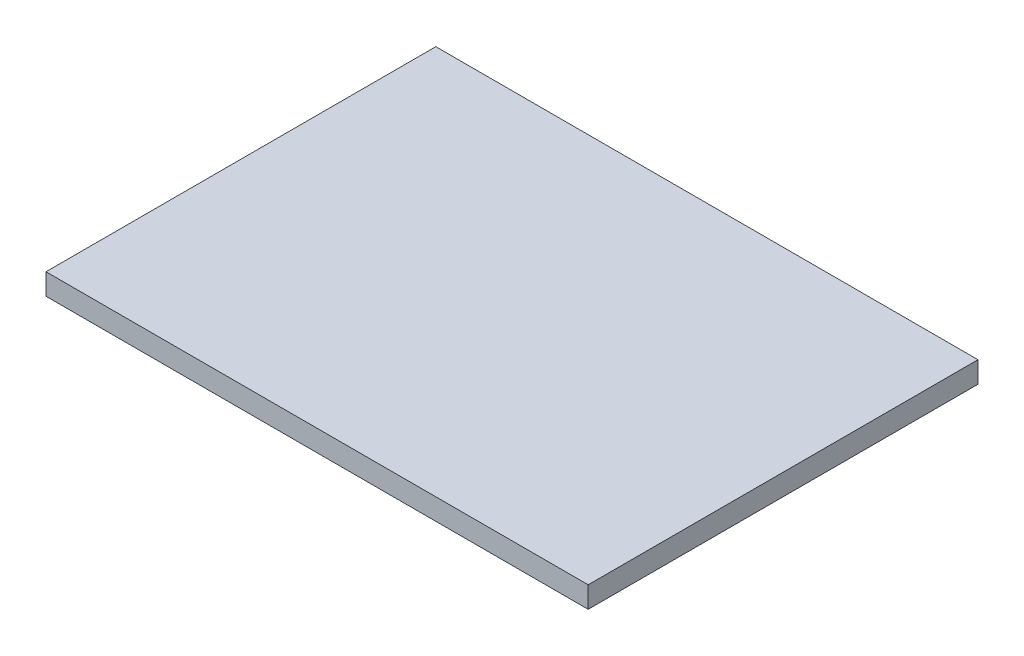
from build123d import *

# Parameters (mm, degrees)
SKETCH1_W           = 153
SKETCH1_H           = 110
BOSS_EXTRUDE1_DEPTH = 6


with BuildPart() as part:
    # Sketch1 → Boss-Extrude1 (new body)
    with BuildSketch(Plane(origin=(0, 0, 0), x_dir=(1, 0, 0), z_dir=(0, 1, 0))):
        with Locations((178.5, 70)):
            Rectangle(SKETCH1_W, SKETCH1_H)
    extrude(amount=BOSS_EXTRUDE1_DEPTH)


solid = part.part
